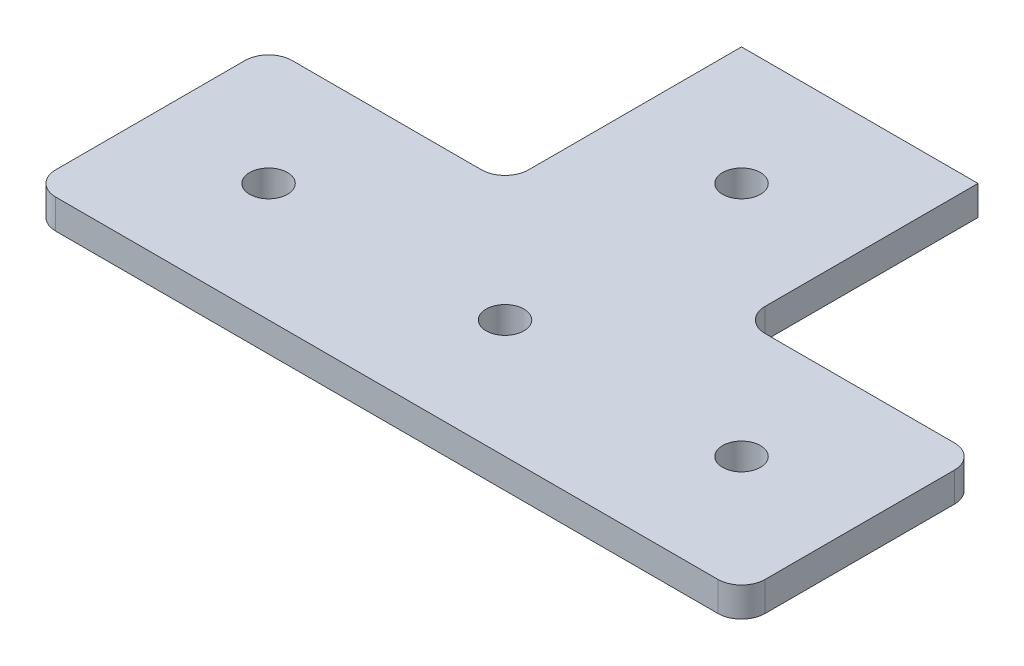
from build123d import *

# Parameters (mm, degrees)
SKETCH1_R           = 2.032
BOSS_EXTRUDE1_DEPTH = 3.175


with BuildPart() as part:
    # Sketch1 → Boss-Extrude1 (new body)
    with BuildSketch(Plane(origin=(0, 0, 0), x_dir=(1, 0, 0), z_dir=(0, 1, 0))):
        with BuildLine():
            Line((18.720543933, 17.495711297), (39.040543933, 17.495711297))
            ThreePointArc((39.040543933, 17.495711297), (40.836595157, 16.751762521), (41.580543933, 14.955711297))
            Line((41.580543933, 14.955711297), (41.580543933, -5.364288703))
            ThreePointArc((41.580543933, -5.364288703), (40.836595157, -7.160339927), (39.040543933, -7.904288703))
            Line((39.040543933, -7.904288703), (-32.079456067, -7.904288703))
            ThreePointArc((-32.079456067, -7.904288703), (-33.875507291, -7.160339927), (-34.619456067, -5.364288703))
            Line((-34.619456067, -5.364288703), (-34.619456067, 14.955711297))
            ThreePointArc((-34.619456067, 14.955711297), (-33.875507291, 16.751762521), (-32.079456067, 17.495711297))
            Line((-32.079456067, 17.495711297), (-11.759456067, 17.495711297))
            ThreePointArc((-11.759456067, 17.495711297), (-9.963404843, 18.239660073), (-9.219456067, 20.035711297))
            Line((-9.219456067, 20.035711297), (-9.219456067, 42.895711297))
            Line((-9.219456067, 42.895711297), (16.180543933, 42.895711297))
            Line((16.180543933, 42.895711297), (16.180543933, 20.035711297))
            ThreePointArc((16.180543933, 20.035711297), (16.924492709, 18.239660073), (18.720543933, 17.495711297))
        make_face()
        with Locations((3.480543933, 4.795711297)):
            Circle(SKETCH1_R, mode=Mode.SUBTRACT)
        with Locations((-21.919456067, 4.795711297)):
            Circle(SKETCH1_R, mode=Mode.SUBTRACT)
        with Locations((28.880543933, 4.795711297)):
            Circle(SKETCH1_R, mode=Mode.SUBTRACT)
        with Locations((3.480543933, 30.195711297)):
            Circle(SKETCH1_R, mode=Mode.SUBTRACT)
    extrude(amount=BOSS_EXTRUDE1_DEPTH)


solid = part.part
